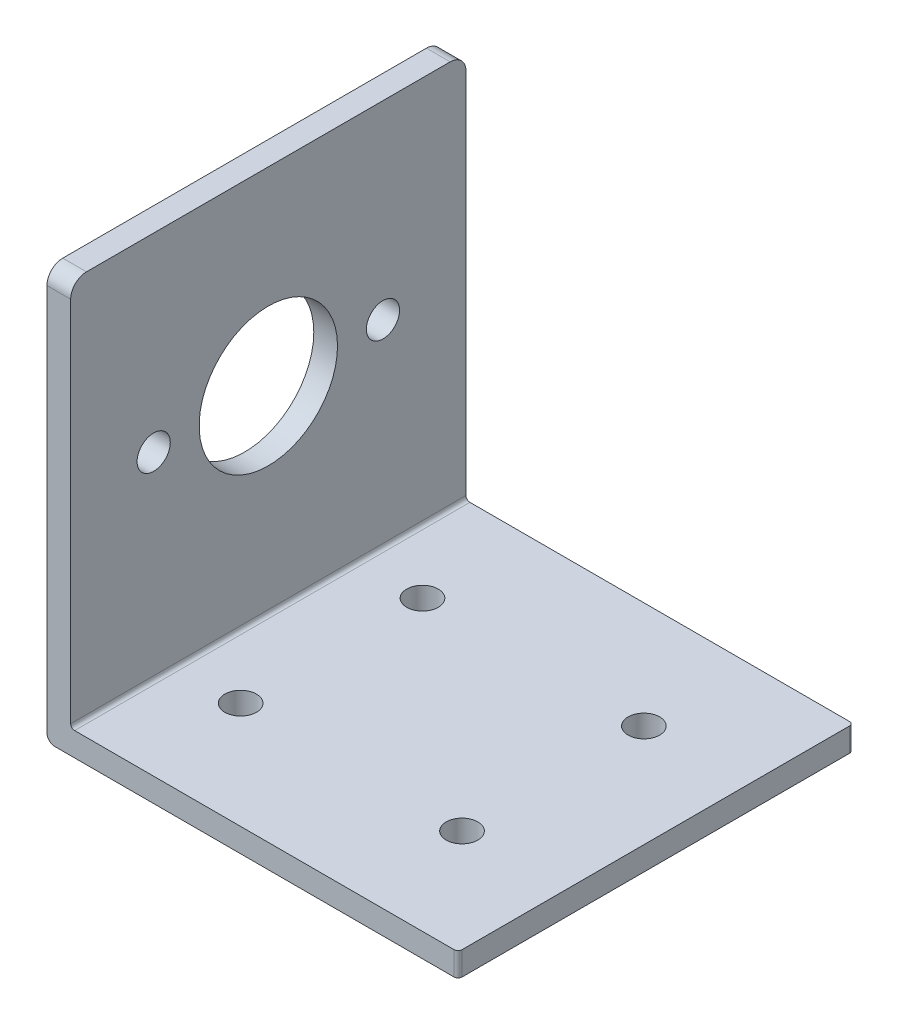
from build123d import *

# Parameters (mm, degrees)
BOSS_EXTRUDE1_DEPTH            = 50
SKETCH2_R                      = 8.75
SKETCH2_R_2                    = 2.1
CUT_EXTRUDE1_DEPTH             = 10
FILLET1_R                      = 2
FILLET2_R                      = 0.5
FILLET3_R                      = 0.5
HOLE_FOR_M4_300_SC_NUTS_SP_1_D = 4


with BuildPart() as part:
    # Sketch1 → Boss-Extrude1 (new body)
    with BuildSketch(Plane.XY):
        with BuildLine():
            Line((0, 0), (0, 49))
            Line((0, 49), (-3, 49))
            Line((-3, 49), (-3, -2))
            ThreePointArc((-3, -2), (-2.707106781, -2.707106781), (-2, -3))
            Line((-2, -3), (49, -3))
            Line((49, -3), (49, 0))
            Line((49, 0), (0, 0))
        make_face()
    extrude(amount=BOSS_EXTRUDE1_DEPTH)

    # Sketch2 → Cut-Extrude1 (cut)
    with BuildSketch(Plane(origin=(0, 0, 0), x_dir=(0, 0, -1), z_dir=(1, 0, 0))):
        with Locations((-25, 25)):
            Circle(SKETCH2_R)
        with Locations((-10.5, 25)):
            Circle(SKETCH2_R_2)
        with Locations((-39.5, 25)):
            Circle(SKETCH2_R_2)
    extrude(amount=-CUT_EXTRUDE1_DEPTH, mode=Mode.SUBTRACT)

    # Fillet1
    fillet1_edges = [part.edges().sort_by_distance(p)[0] for p in [
        (-1.5, 49, 50),
        (-1.5, 49, 0),
    ]]
    fillet(fillet1_edges, radius=FILLET1_R)

    # Fillet2
    fillet2_edges = [part.edges().sort_by_distance(p)[0] for p in [
        (0, 0, 25),
    ]]
    fillet(fillet2_edges, radius=FILLET2_R)

    # Fillet3
    fillet3_edges = [part.edges().sort_by_distance(p)[0] for p in [
        (49, -1.5, 50),
        (49, -1.5, 0),
    ]]
    fillet(fillet3_edges, radius=FILLET3_R)

    # Hole for M4 300® SC Nuts (SP)1 (through all)
    with Locations(Plane(origin=(0, 0, 0), x_dir=(1, 0, 0), z_dir=(0, 1, 0))):
        with Locations((36, -13.5), (8, -13.5), (36, -36.5), (8, -36.5)):
            Hole(HOLE_FOR_M4_300_SC_NUTS_SP_1_D / 2)


solid = part.part
